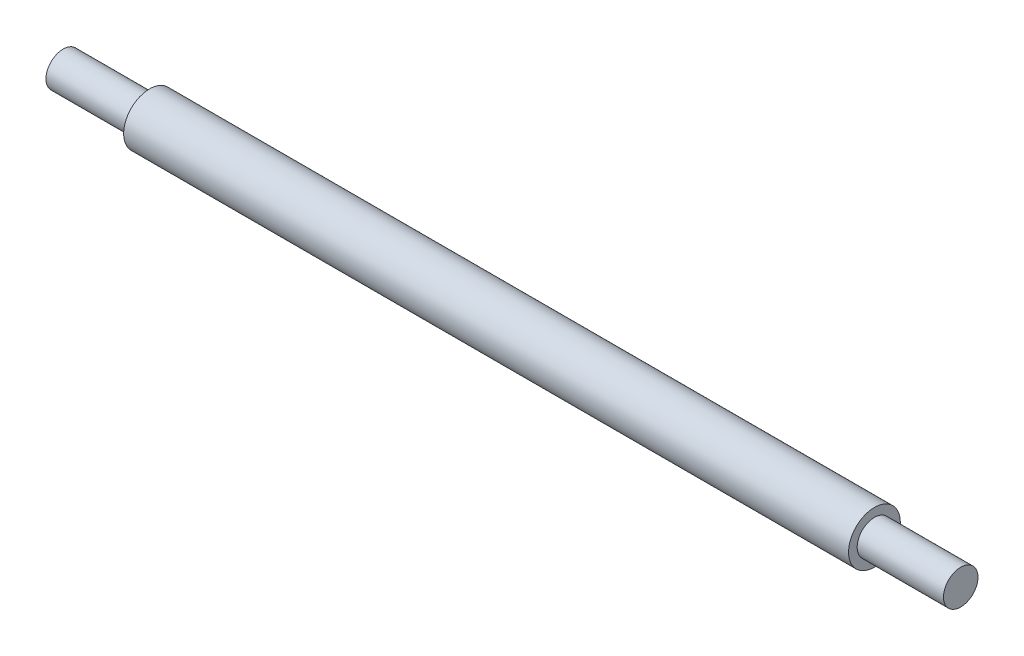
from build123d import *


with BuildPart() as part:
    # Sketch1 → Revolve1 (revolve)
    with BuildSketch(Plane.XY):
        Polygon((0, 0), (0, 2), (10, 2), (10, 3), (94, 3), (94, 2), (104, 2), (104, 0), align=None)
    revolve(axis=Axis((0, 0, 0), (-1, 0, 0)))


solid = part.part
